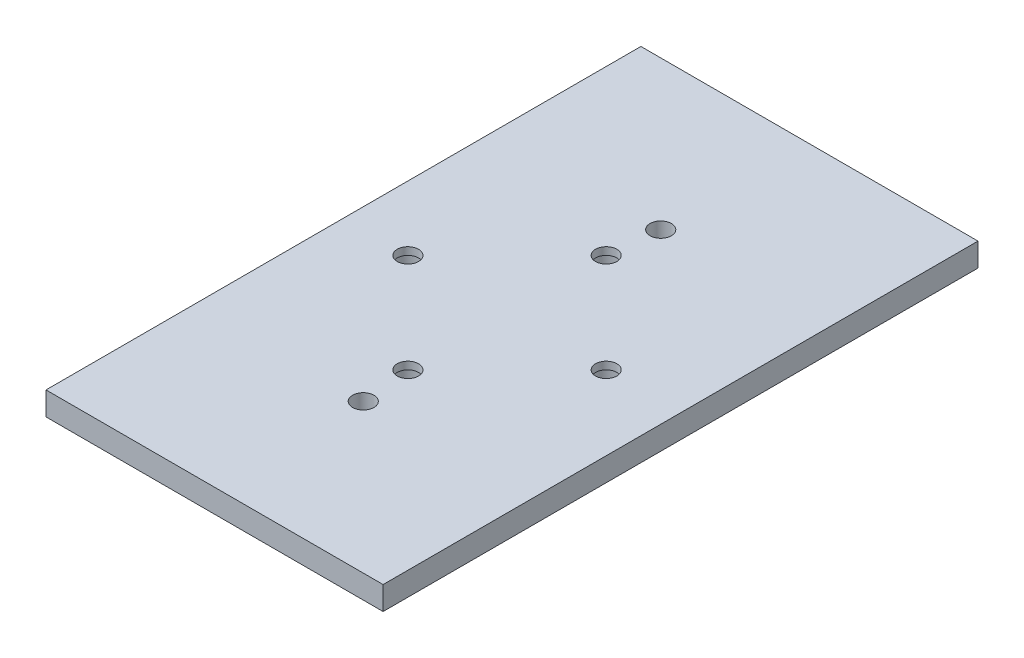
from build123d import *

# Parameters (mm, degrees)
SKETCH2_W               = 88.9
SKETCH2_H               = 152.4
BOSS_EXTRUDE1_DEPTH     = 5.9944
SKETCH4_R               = 2.7305
CUT_EXTRUDE2_DEPTH      = 1
CUT_EXTRUDE2_DEPTH_BACK = 6.9944
SKETCH5_R               = 2.7305
CUT_EXTRUDE3_DEPTH      = 1
CUT_EXTRUDE3_DEPTH_BACK = 6.9944
SKETCH7_W               = 2.54
SKETCH7_H               = 152.4
CUT_EXTRUDE5_DEPTH      = 1
CUT_EXTRUDE5_DEPTH_BACK = 6.9944
SKETCH8_R               = 3.683
CUT_EXTRUDE6_DEPTH      = 4.064


with BuildPart() as part:
    # Sketch2 → Boss-Extrude1 (new body)
    with BuildSketch(Plane(origin=(0, 0, 0), x_dir=(1, 0, 0), z_dir=(0, 1, 0))):
        with Locations((44.45, 76.2)):
            Rectangle(SKETCH2_W, SKETCH2_H)
    extrude(amount=BOSS_EXTRUDE1_DEPTH)

    # Sketch4 → Cut-Extrude2 (cut, two sides)
    with BuildSketch(Plane(origin=(0, 5.9944, 0), x_dir=(1, 0, 0), z_dir=(0, 1, 0))) as cut_extrude2_sk:
        with Locations((45.72, 114.3)):
            Circle(SKETCH4_R)
        with Locations((45.72, 38.1)):
            Circle(SKETCH4_R)
    extrude(amount=CUT_EXTRUDE2_DEPTH, mode=Mode.SUBTRACT)
    extrude(cut_extrude2_sk.sketch, amount=-CUT_EXTRUDE2_DEPTH_BACK, mode=Mode.SUBTRACT)

    # Sketch5 → Cut-Extrude3 (cut, two sides)
    with BuildSketch(Plane(origin=(0, 5.9944, 0), x_dir=(1, 0, 0), z_dir=(0, 1, 0))) as cut_extrude3_sk:
        with Locations((69.85, 76.2)):
            Circle(SKETCH5_R)
        with Locations((19.05, 76.2)):
            Circle(SKETCH5_R)
        with Locations((44.45, 101.6)):
            Circle(SKETCH5_R)
        with Locations((44.45, 50.8)):
            Circle(SKETCH5_R)
    extrude(amount=CUT_EXTRUDE3_DEPTH, mode=Mode.SUBTRACT)
    extrude(cut_extrude3_sk.sketch, amount=-CUT_EXTRUDE3_DEPTH_BACK, mode=Mode.SUBTRACT)

    # Sketch7 → Cut-Extrude5 (cut, two sides)
    with BuildSketch(Plane(origin=(0, 5.9944, 0), x_dir=(1, 0, 0), z_dir=(0, 1, 0))) as cut_extrude5_sk:
        with Locations((1.27, 76.2)):
            Rectangle(SKETCH7_W, SKETCH7_H)
    extrude(amount=CUT_EXTRUDE5_DEPTH, mode=Mode.SUBTRACT)
    extrude(cut_extrude5_sk.sketch, amount=-CUT_EXTRUDE5_DEPTH_BACK, mode=Mode.SUBTRACT)

    # Sketch8 → Cut-Extrude6 (cut)
    with BuildSketch(Plane.XZ):
        with Locations((19.05, -76.2)):
            Circle(SKETCH8_R)
        with Locations((44.45, -50.8)):
            Circle(SKETCH8_R)
        with Locations((69.85, -76.2)):
            Circle(SKETCH8_R)
        with Locations((44.45, -101.6)):
            Circle(SKETCH8_R)
    extrude(amount=-CUT_EXTRUDE6_DEPTH, mode=Mode.SUBTRACT)


solid = part.part
